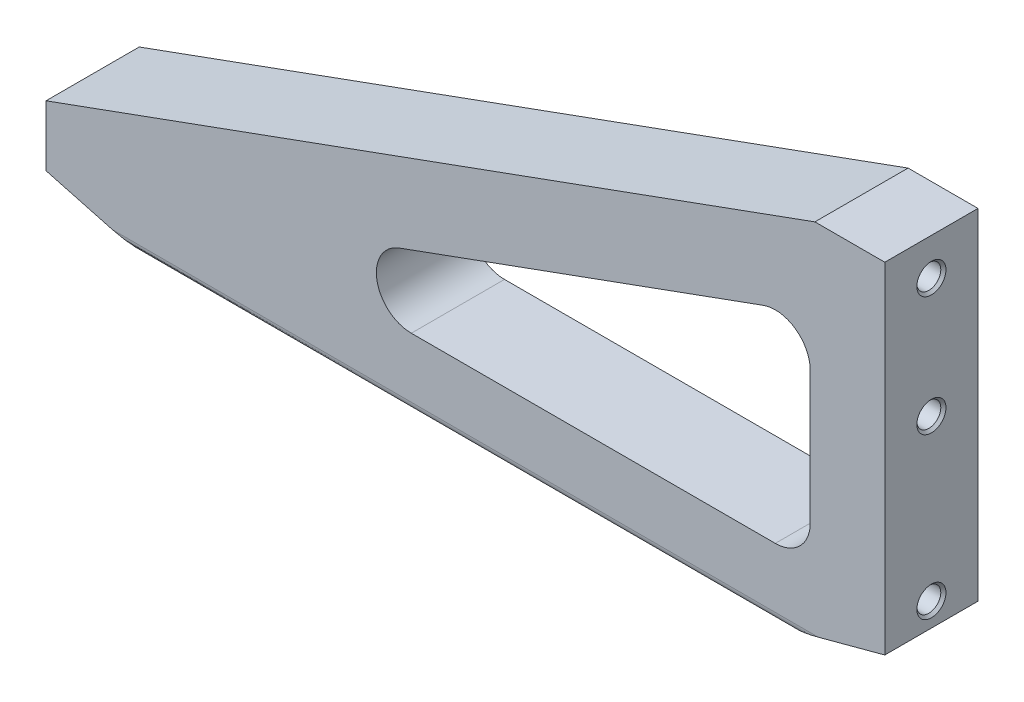
from build123d import *

# Parameters (mm, degrees)
BOSS_EXTRUDE1_DEPTH                = 12.7
F_5_16_18_TAPPED_HOLE1_D           = 6.5278
F_5_16_18_TAPPED_HOLE1_DEPTH       = 20.1168
F_5_16_18_TAPPED_HOLE1_CSINK_D     = 7.9375
F_5_16_18_TAPPED_HOLE1_CSINK_ANGLE = 90
F_5_16_18_TAPPED_HOLE1_TIP         = 1.961148974
SKETCH8_OUTSIDE_W                  = 77.69
SKETCH8_OUTSIDE_H                  = 153.891
CUT_EXTRUDE1_DEPTH                 = 229.6
FILLET1_R                          = 2.38125


with BuildPart() as part:
    # Sketch1 w/mock PCB → Boss-Extrude1 (new body, symmetric)
    with BuildSketch(Plane.XY):
        Polygon((-19.05, 48.1965), (-228.6, -28.0035), (-228.6, -44.5135), (-195.422068321, -53.4035), (-33.177931679, -53.4035), (0, -44.5135), (0, 48.1965), align=None)
        with BuildLine():
            Line((-20.32, 12.51406647), (-20.32, -23.5585))
            ThreePointArc((-20.32, -23.5585), (-23.109807909, -30.293692091), (-29.845, -33.0835))
            Line((-29.845, -33.0835), (-129.044557791, -33.0835))
            ThreePointArc((-129.044557791, -33.0835), (-138.425095375, -25.211115999), (-132.299660467, -14.606967641))
            Line((-132.299660467, -14.606967641), (-33.100102676, 21.465598828))
            ThreePointArc((-33.100102676, 21.465598828), (-24.380534243, 20.315684186), (-20.32, 12.51406647))
        make_face(mode=Mode.SUBTRACT)
    extrude(amount=BOSS_EXTRUDE1_DEPTH, both=True)

    # 5/16-18 Tapped Hole1
    with Locations(Plane(origin=(0, 31.393459191, 0.765177918), x_dir=(0, 0, 1), z_dir=(1, 0, 0))):
        with Locations((-0.765177918, 69.493459191), (-0.765177918, 25.856259191), (-0.765177918, -6.706540809)):
            CounterSinkHole(F_5_16_18_TAPPED_HOLE1_D / 2, F_5_16_18_TAPPED_HOLE1_CSINK_D / 2, depth=F_5_16_18_TAPPED_HOLE1_DEPTH, counter_sink_angle=F_5_16_18_TAPPED_HOLE1_CSINK_ANGLE)
            with Locations((0, 0, -(F_5_16_18_TAPPED_HOLE1_DEPTH + F_5_16_18_TAPPED_HOLE1_TIP / 2))):  # 118° drill point
                Cone(0, F_5_16_18_TAPPED_HOLE1_D / 2, F_5_16_18_TAPPED_HOLE1_TIP, mode=Mode.SUBTRACT)

    # Sketch8 outside → Cut-Extrude1 (cut, through all)
    with BuildSketch(Plane(origin=(0, 0, 0), x_dir=(0, 0, -1), z_dir=(1, 0, 0))):
        with Locations((0, -2.6035)):
            Rectangle(SKETCH8_OUTSIDE_W, SKETCH8_OUTSIDE_H)
        with BuildLine():
            Line((12.7, 48.1965), (12.7, -51.725281086))
            ThreePointArc((12.7, -51.725281086), (0, -51.816), (-12.7, -51.725281086))
            Line((-12.7, -51.725281086), (-12.7, 48.1965))
            Line((-12.7, 48.1965), (12.7, 48.1965))
        make_face(mode=Mode.SUBTRACT)
    extrude(amount=-CUT_EXTRUDE1_DEPTH, mode=Mode.SUBTRACT)

    # Fillet1
    fillet1_edges = [part.edges().sort_by_distance(p)[0] for p in [
        (-114.3, -51.725281086, -12.7),
        (-114.3, -51.725281086, 12.7),
    ]]
    fillet(fillet1_edges, radius=FILLET1_R)


solid = part.part
